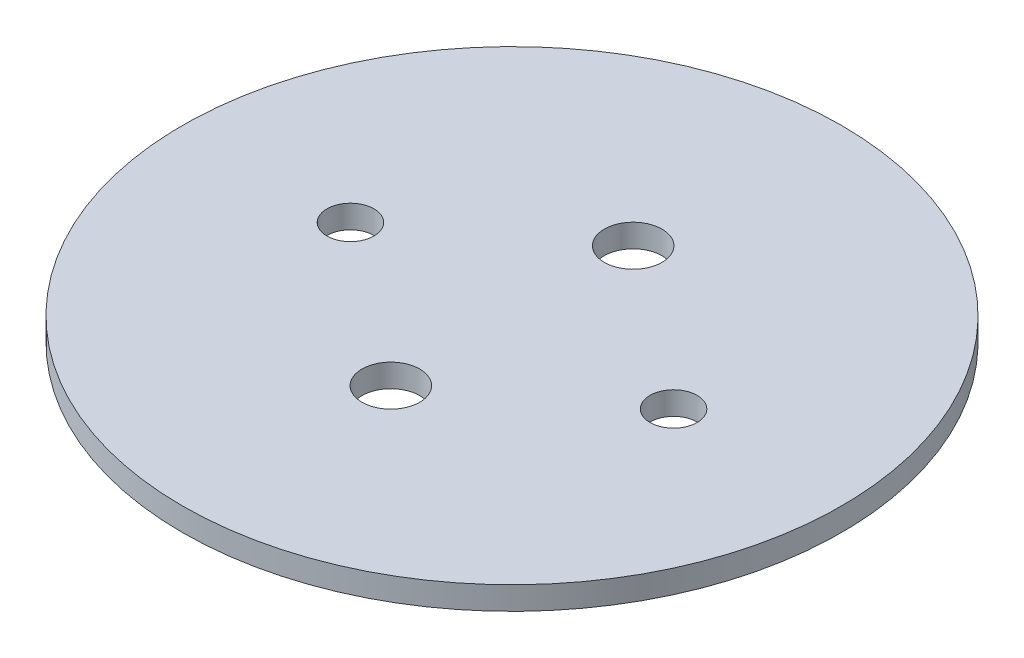
from build123d import *

# Parameters (mm, degrees)
SKETCH1_R           = 45.339
SKETCH1_R_2         = 3.2385
SKETCH1_R_3         = 3.96875
BOSS_EXTRUDE1_DEPTH = 3.175


with BuildPart() as part:
    # Sketch1 → Boss-Extrude1 (new body)
    with BuildSketch(Plane(origin=(0, 0, 0), x_dir=(1, 0, 0), z_dir=(0, 1, 0))):
        Circle(SKETCH1_R)
        with Locations((22.225, 0)):
            Circle(SKETCH1_R_2, mode=Mode.SUBTRACT)
        with Locations((-22.225, 0)):
            Circle(SKETCH1_R_2, mode=Mode.SUBTRACT)
        with Locations((0, 16.66875)):
            Circle(SKETCH1_R_3, mode=Mode.SUBTRACT)
        with Locations((0, -16.66875)):
            Circle(SKETCH1_R_3, mode=Mode.SUBTRACT)
    extrude(amount=BOSS_EXTRUDE1_DEPTH)


solid = part.part
